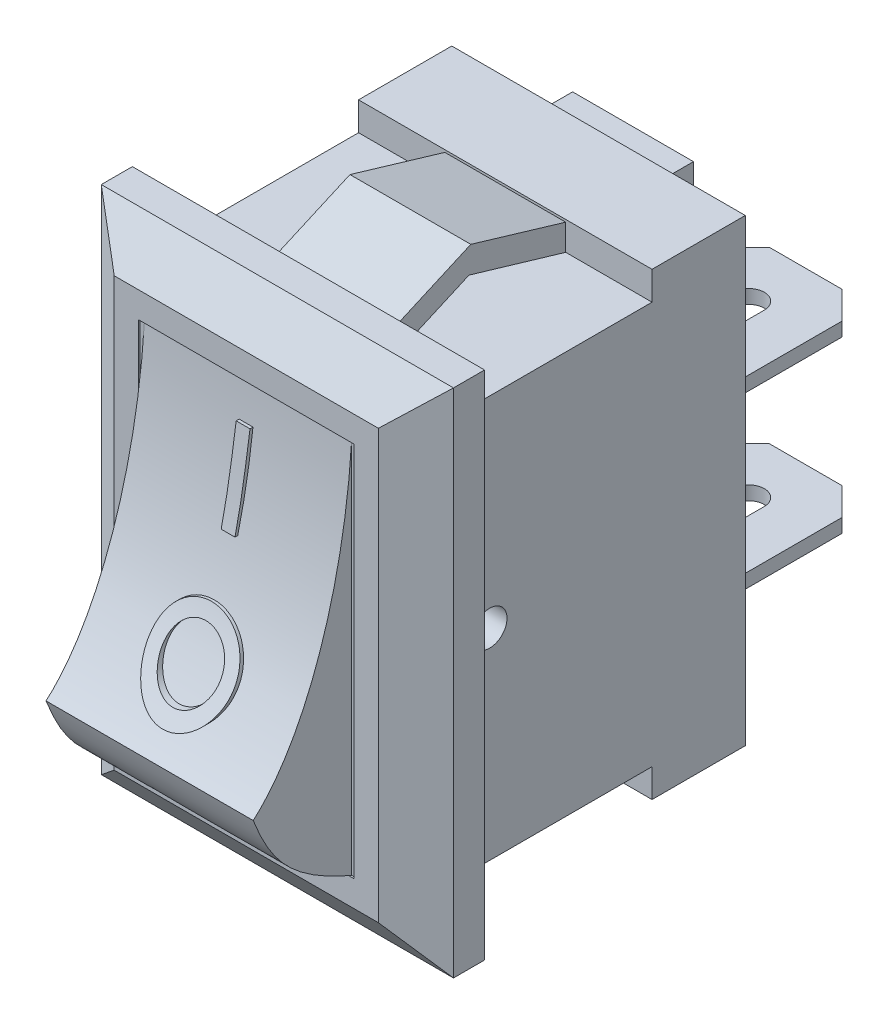
from build123d import *

# Parameters (mm, degrees)
SKETCH1_W                = 10.2
SKETCH1_H                = 14.8
BOSS_EXTRUDE1_DEPTH      = 1.8
SKETCH2_W                = 6.25
SKETCH2_H                = 10.9
CUT_EXTRUDE1_DEPTH       = 0.05
CUT_EXTRUDE2_DEPTH       = 6.1
CUT_EXTRUDE3_DEPTH       = 8.4
BOSS_EXTRUDE2_DEPTH      = 4.25
BOSS_EXTRUDE2_DEPTH_BACK = 4.25
SKETCH7_W                = 3.5
SKETCH7_H                = 2.65
BOSS_EXTRUDE3_DEPTH      = 1
SKETCH8_W                = 6.7
SKETCH8_H                = 2.65
BOSS_EXTRUDE4_DEPTH      = 0.2
SKETCH12_W               = 3.7
SKETCH12_H               = 0.4
BOSS_EXTRUDE5_DEPTH      = 5
BOSS_EXTRUDE5_DEPTH_BACK = 1.5
CHAMFER1_SIZE            = 0.8
CUT_EXTRUDE4_DEPTH       = 8.6
BOSS_EXTRUDE6_DEPTH      = 1.75
SKETCH15_R               = 0.5
CUT_EXTRUDE5_DEPTH       = 1
BOSS_EXTRUDE7_DEPTH      = 3
BOSS_EXTRUDE7_DEPTH_BACK = 3
SKETCH17_R               = 1.25
SKETCH17_R_2             = 0.85
SKETCH17_W               = 0.4
SKETCH17_H               = 2.5
BOSS_EXTRUDE10_DEPTH     = 3
CUT_EXTRUDE6_DEPTH       = 9.1


with BuildPart() as part:
    # Sketch1 → Boss-Extrude1 (new body)
    with BuildSketch(Plane.XY):
        Rectangle(SKETCH1_W, SKETCH1_H)
    extrude(amount=BOSS_EXTRUDE1_DEPTH)

    # Sketch2 → Cut-Extrude1 (cut)
    with BuildSketch(Plane.XY.offset(1.8)):
        Rectangle(SKETCH2_W, SKETCH2_H)
    extrude(amount=-CUT_EXTRUDE1_DEPTH, mode=Mode.SUBTRACT)

    # Sketch4 → Cut-Extrude2 (cut, symmetric)
    with BuildSketch(Plane(origin=(0, 0, 0), x_dir=(0, 0, -1), z_dir=(1, 0, 0))):
        Polygon((-1.8, 6.2), (-0.9, 7.4), (-1.8, 7.4), align=None)
    cut_extrude2 = extrude(amount=CUT_EXTRUDE2_DEPTH, both=True, mode=Mode.SUBTRACT)

    # Mirror1: Cut-Extrude2 across plane
    add(cut_extrude2.mirror(Plane.ZX), mode=Mode.SUBTRACT)

    # Sketch5 → Cut-Extrude3 (cut, symmetric)
    with BuildSketch(Plane(origin=(0, 0, 0), x_dir=(1, 0, 0), z_dir=(0, 1, 0))):
        Polygon((-5.1, -1.8), (-3.825, -1.8), (-5.1, -0.9), align=None)
    cut_extrude3 = extrude(amount=CUT_EXTRUDE3_DEPTH, both=True, mode=Mode.SUBTRACT)

    # Mirror2: Cut-Extrude3 across plane
    add(cut_extrude3.mirror(Plane(origin=(0, 0, 0), x_dir=(0, 0, 1), z_dir=(1, 0, 0))), mode=Mode.SUBTRACT)

    # Sketch6 → Boss-Extrude2 (add, two sides)
    with BuildSketch(Plane(origin=(0, 0, 0), x_dir=(0, 0, -1), z_dir=(1, 0, 0))) as boss_extrude2_sk:
        Polygon((0, 5.825), (5.7, 5.825), (5.7, 6.65), (8.4, 6.65), (8.4, -6.65), (5.7, -6.65), (5.7, -5.825), (0, -5.825), align=None)
    extrude(amount=BOSS_EXTRUDE2_DEPTH)
    extrude(boss_extrude2_sk.sketch, amount=-BOSS_EXTRUDE2_DEPTH_BACK)

    # Sketch7 → Boss-Extrude3 (add)
    with BuildSketch(Plane(origin=(0, 0, -8.4), x_dir=(-1, 0, 0), z_dir=(0, 0, -1))):
        with Locations((0, 4.925)):
            Rectangle(SKETCH7_W, SKETCH7_H)
        Rectangle(SKETCH7_W, SKETCH7_H)
        with Locations((0, -4.925)):
            Rectangle(SKETCH7_W, SKETCH7_H)
    extrude(amount=BOSS_EXTRUDE3_DEPTH)

    # Sketch8 → Boss-Extrude4 (add)
    with BuildSketch(Plane(origin=(0, 0, -8.4), x_dir=(-1, 0, 0), z_dir=(0, 0, -1))):
        with Locations((0, 4.925)):
            Rectangle(SKETCH8_W, SKETCH8_H)
        Rectangle(SKETCH8_W, SKETCH8_H)
        with Locations((0, -4.925)):
            Rectangle(SKETCH8_W, SKETCH8_H)
    extrude(amount=BOSS_EXTRUDE4_DEPTH)

    # Sketch12 → Boss-Extrude5 (add, two sides)
    with BuildSketch(Plane(origin=(0, 0, -9.4), x_dir=(-1, 0, 0), z_dir=(0, 0, -1))) as boss_extrude5_sk:
        Rectangle(SKETCH12_W, SKETCH12_H)
        with Locations((0, -4.925)):
            Rectangle(SKETCH12_W, SKETCH12_H)
    extrude(amount=BOSS_EXTRUDE5_DEPTH)
    extrude(boss_extrude5_sk.sketch, amount=-BOSS_EXTRUDE5_DEPTH_BACK)

    # Chamfer1
    chamfer1_edges = [part.edges().sort_by_distance(p)[0] for p in [
        (1.85, 0, -8.6),
        (-1.85, 0, -8.6),
        (1.85, 0, -14.4),
        (-1.85, 0, -14.4),
        (1.85, -4.925, -8.6),
        (-1.85, -4.925, -8.6),
        (1.85, -4.925, -14.4),
        (-1.85, -4.925, -14.4),
    ]]
    chamfer(chamfer1_edges, length=CHAMFER1_SIZE)

    # Sketch13 → Cut-Extrude4 (cut, through all)
    with BuildSketch(Plane(origin=(0, 0.2, 0), x_dir=(1, 0, 0), z_dir=(0, 1, 0))):
        with BuildLine():
            Line((0.45, 12.75), (0.45, 11.55))
            ThreePointArc((0.45, 11.55), (0, 11.1), (-0.45, 11.55))
            Line((-0.45, 11.55), (-0.45, 12.75))
            ThreePointArc((-0.45, 12.75), (0, 13.2), (0.45, 12.75))
        make_face()
    extrude(amount=-CUT_EXTRUDE4_DEPTH, mode=Mode.SUBTRACT)

    # Sketch14 → Boss-Extrude6 (add, symmetric)
    with BuildSketch(Plane(origin=(0, 0, 0), x_dir=(0, 0, -1), z_dir=(1, 0, 0))):
        Polygon((5.7, 6.581901118), (2.951211879, 7.4), (0, 6.096596717), (0, 5.825), (1.022149578, 5.825), (2.89851051, 6.65369516), (5.7, 5.825), align=None)
    boss_extrude6 = extrude(amount=BOSS_EXTRUDE6_DEPTH, both=True)

    # Mirror3: Boss-Extrude6 across plane
    add(boss_extrude6.mirror(Plane.ZX))

    # Sketch15 → Cut-Extrude5 (cut)
    with BuildSketch(Plane(origin=(4.25, 0, 0), x_dir=(0, 0, -1), z_dir=(1, 0, 0))):
        with Locations((1, 0)):
            Circle(SKETCH15_R)
    cut_extrude5 = extrude(amount=-CUT_EXTRUDE5_DEPTH, mode=Mode.SUBTRACT)

    # Mirror4: Cut-Extrude5 across plane
    add(cut_extrude5.mirror(Plane(origin=(0, 0, 0), x_dir=(0, 0, 1), z_dir=(1, 0, 0))), mode=Mode.SUBTRACT)

    # Sketch16 → Boss-Extrude7 (add, two sides)
    with BuildSketch(Plane(origin=(0, 0, 0), x_dir=(0, 0, -1), z_dir=(1, 0, 0))) as boss_extrude7_sk:
        with BuildLine():
            Line((-1.75, 5.45), (-1.75, -5.45))
            add(Edge.make_bspline(
                [(-1.75, -5.45), (-3.529930344, -4.698713531), (-4.113957414, -3.89718415), (-4.6, -2.65)],
                knots=[0, 0, 0, 0, 1, 1, 1, 1], degree=3))
            add(Edge.make_bspline(
                [(-4.6, -2.65), (-3.045765396, -1.290380774), (-1.96741903, 1.96934222), (-1.75, 5.45)],
                knots=[0, 0, 0, 0, 1, 1, 1, 1], degree=3))
        make_face()
    extrude(amount=BOSS_EXTRUDE7_DEPTH)
    extrude(boss_extrude7_sk.sketch, amount=-BOSS_EXTRUDE7_DEPTH_BACK)

    # Sketch17 → Boss-Extrude10 (add)
    with BuildSketch(Plane.XY.offset(1.81)):
        with Locations((0, -0.8)):
            Circle(SKETCH17_R)
        with Locations((0, -0.8)):
            Circle(SKETCH17_R_2, mode=Mode.SUBTRACT)
        with Locations((0.029387381, 3.2)):
            Rectangle(SKETCH17_W, SKETCH17_H)
    extrude(amount=BOSS_EXTRUDE10_DEPTH)

    # Sketch18 → Cut-Extrude6 (cut, through all)
    with BuildSketch(Plane(origin=(3, 0, 0), x_dir=(0, 0, -1), z_dir=(1, 0, 0))):
        with BuildLine():
            Line((-1.9, 4.608608478), (-5.877914131, 4.608608478))
            Line((-5.877914131, 4.608608478), (-5.877914131, -2.397848694))
            Line((-5.877914131, -2.397848694), (-4.5, -2.397848694))
            add(Edge.make_bspline(
                [(-1.9, 4.608608478), (-2.290337518, 1.868608993), (-2.609137058, -0.12015973), (-4.5, -2.397848694)],
                knots=[0, 0, 0, 0, 1, 1, 1, 1], degree=3))
        make_face()
    extrude(amount=-CUT_EXTRUDE6_DEPTH, mode=Mode.SUBTRACT)


solid = part.part
